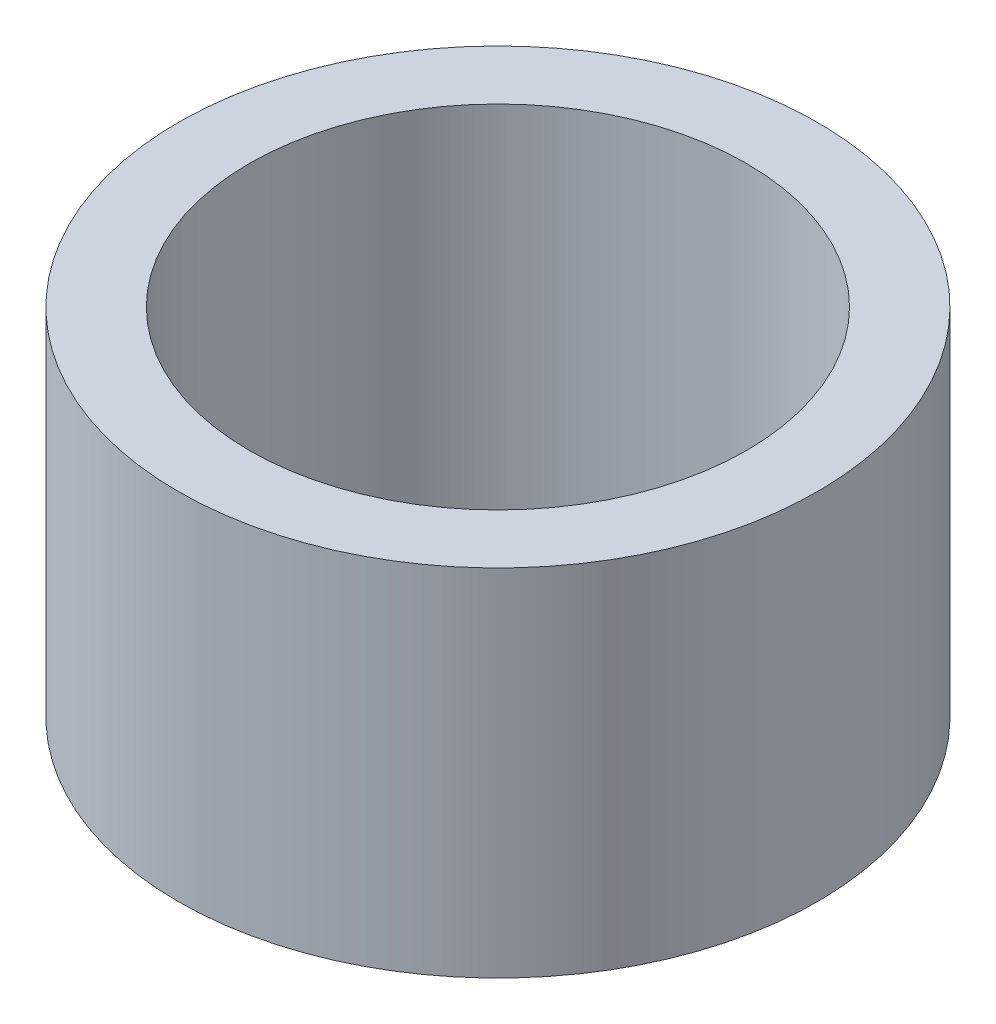
from build123d import *

# Parameters (mm, degrees)
SKETCH_1_R      = 45
SKETCH_1_R_2    = 35
EXTRUDE_1_DEPTH = 50


with BuildPart() as part:
    # Эскиз1 → Бобышка-Вытянуть1 (new body)
    with BuildSketch(Plane(origin=(0, 0, 0), x_dir=(1, 0, 0), z_dir=(0, 1, 0))):
        Circle(SKETCH_1_R)
        Circle(SKETCH_1_R_2, mode=Mode.SUBTRACT)
    extrude(amount=EXTRUDE_1_DEPTH)


solid = part.part
